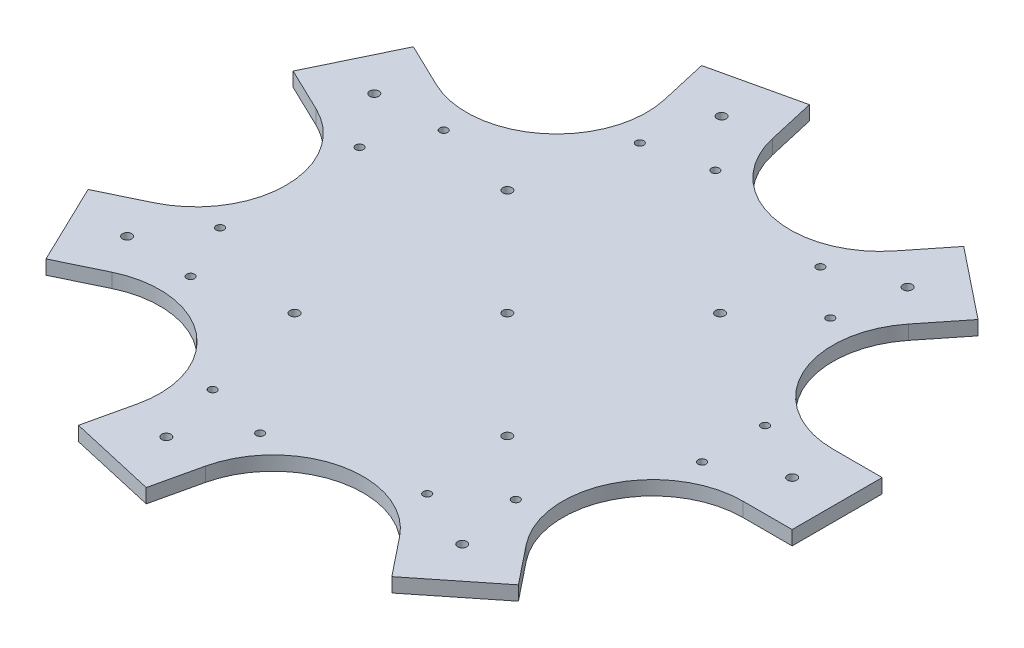
from build123d import *

# Parameters (mm, degrees)
SKETCH3_W           = 232.55
SKETCH3_H           = 63.5
SKETCH3_R           = 3.25
SKETCH3_R_2         = 2.778125
BOSS_EXTRUDE1_DEPTH = 10
CIRPATTERN1_COUNT   = 7
FILLET1_R           = 63.5
SKETCH5_R           = 3.25
CUT_EXTRUDE4_DEPTH  = 11


with BuildPart() as part:
    # Sketch3 → Boss-Extrude1 (new body)
    with BuildSketch(Plane(origin=(0, 0, 0), x_dir=(1, 0, 0), z_dir=(0, 1, 0))):
        with Locations((116.275, 0)):
            Rectangle(SKETCH3_W, SKETCH3_H)
        with Locations((200.8, 0)):
            Circle(SKETCH3_R, mode=Mode.SUBTRACT)
        with Locations((159.525, 22.225)):
            Circle(SKETCH3_R_2, mode=Mode.SUBTRACT)
        with Locations((159.525, -22.225)):
            Circle(SKETCH3_R_2, mode=Mode.SUBTRACT)
    boss_extrude1 = extrude(amount=BOSS_EXTRUDE1_DEPTH)

    # CirPattern1: Boss-Extrude1 ×7 about axis
    cirpattern1_axis = Axis((0, 0, 0), (0, 1, 0))
    for i in range(1, CIRPATTERN1_COUNT):
        add(boss_extrude1.rotate(cirpattern1_axis, i * 360 / CIRPATTERN1_COUNT))

    # Fillet1
    fillet1_edges = [part.edges().sort_by_distance(p)[0] for p in [
        (65.929554341, 5, 31.75),
        (65.929554341, 5, -31.75),
        (16.283255204, 5, 71.341602418),
        (-45.624667219, 5, 57.211523112),
        (-73.176284653, 5, 0),
        (-45.624667219, 5, -57.211523112),
        (16.283255204, 5, -71.341602418),
    ]]
    fillet(fillet1_edges, radius=FILLET1_R)

    # Sketch5 → Cut-Extrude4 (cut, through all)
    with BuildSketch(Plane(origin=(0, 0, 0), x_dir=(1, 0, 0), z_dir=(0, 1, 0))):
        with Locations((-75, 75)):
            Circle(SKETCH5_R)
        with Locations((75, 75)):
            Circle(SKETCH5_R)
        with Locations((75, -75)):
            Circle(SKETCH5_R)
        with Locations((-75, -75)):
            Circle(SKETCH5_R)
        Circle(SKETCH5_R)
    extrude(amount=CUT_EXTRUDE4_DEPTH, mode=Mode.SUBTRACT)


solid = part.part
